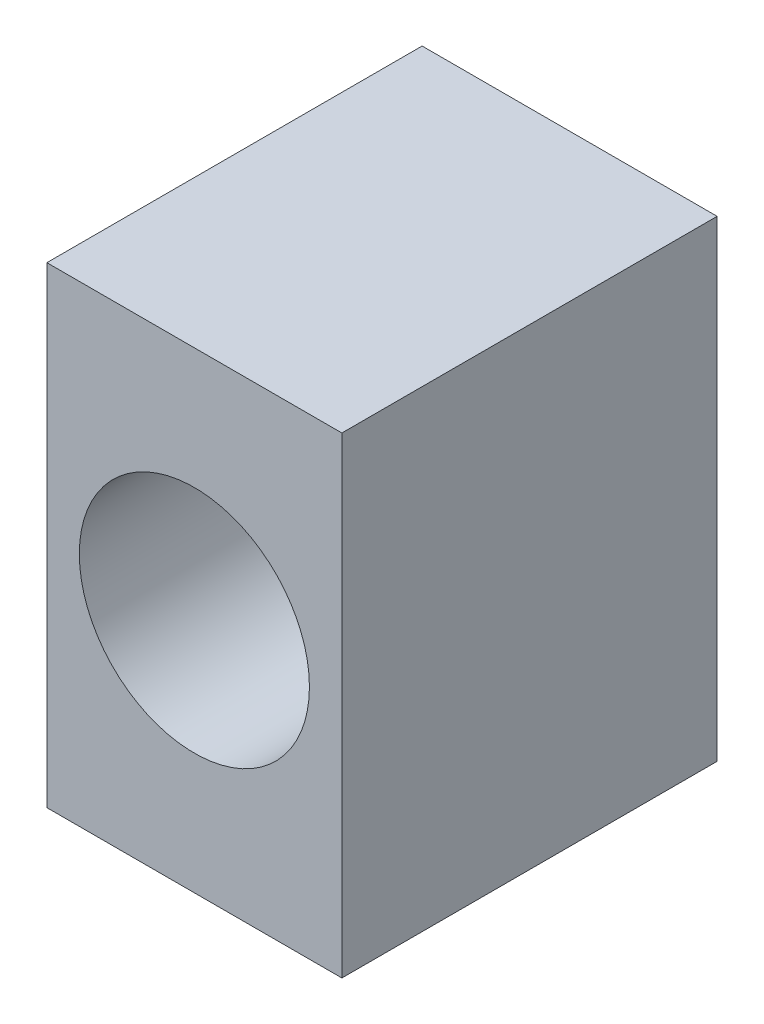
from build123d import *

# Parameters (mm, degrees)
SKETCH2_W           = 2.5
SKETCH2_H           = 4
BOSS_EXTRUDE1_DEPTH = 3.18
SKETCH3_R           = 0.975
CUT_EXTRUDE1_DEPTH  = 4.18


with BuildPart() as part:
    # Sketch2 → Boss-Extrude1 (new body)
    with BuildSketch(Plane.XY):
        Rectangle(SKETCH2_W, SKETCH2_H)
    extrude(amount=BOSS_EXTRUDE1_DEPTH)

    # Sketch3 → Cut-Extrude1 (cut, through all)
    with BuildSketch(Plane.XY.offset(3.18)):
        Circle(SKETCH3_R)
    extrude(amount=-CUT_EXTRUDE1_DEPTH, mode=Mode.SUBTRACT)


solid = part.part
